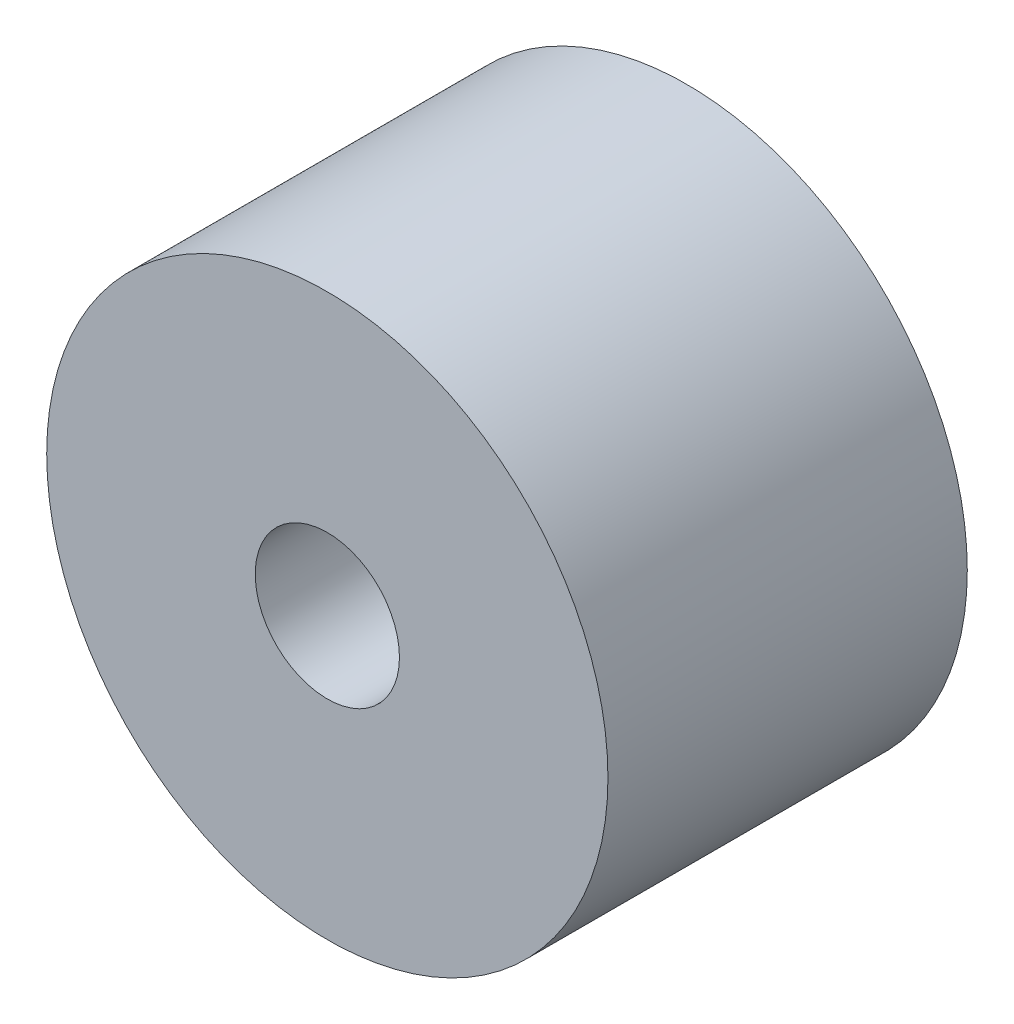
from build123d import *

# Parameters (mm, degrees)
SKETCH1_R           = 2.335
SKETCH1_R_2         = 0.6
BOSS_EXTRUDE1_DEPTH = 2.99


with BuildPart() as part:
    # Sketch1 → Boss-Extrude1 (new body)
    with BuildSketch(Plane.XY):
        Circle(SKETCH1_R)
        Circle(SKETCH1_R_2, mode=Mode.SUBTRACT)
    extrude(amount=BOSS_EXTRUDE1_DEPTH)


solid = part.part
